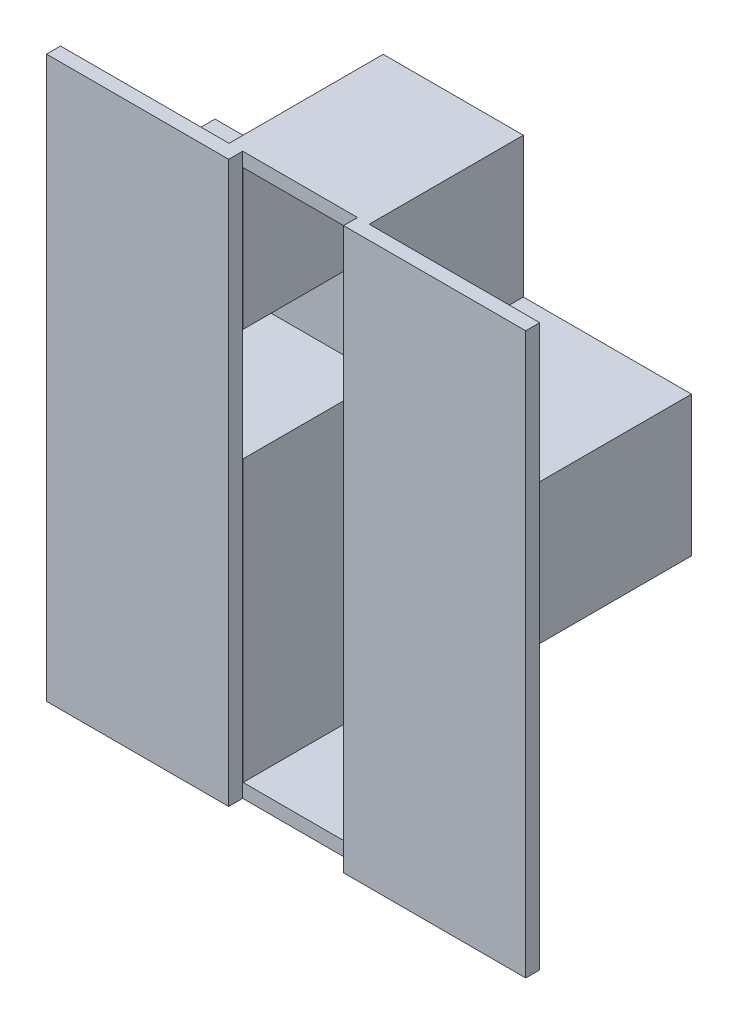
from build123d import *

# Parameters (mm, degrees)
BOSS_EXTRU_2_DEPTH = 5
BOSS_EXTRU_3_DEPTH = 50
ESQUISSE3_W        = 65
ESQUISSE3_H        = 200
BOSS_EXTRU_7_DEPTH = 5
ESQUISSE8_W        = 65
ESQUISSE8_H        = 200
BOSS_EXTRU_8_DEPTH = 5


with BuildPart() as part:
    # Esquisse1 → Boss.-Extru.2 (new body)
    with BuildSketch(Plane.XY):
        Polygon((-50, 100), (-110, 100), (-110, 150), (-50, 150), (-50, 200), (0, 200), (0, 150), (60, 150), (60, 100), (0, 100), (0, 0), (-50, 0), align=None)
    extrude(amount=BOSS_EXTRU_2_DEPTH)

    # Esquisse2 → Boss.-Extru.3 (add)
    with BuildSketch(Plane.XY.offset(5)):
        Polygon((-110, 150), (-110, 100), (-50, 100), (-50, 0), (0, 0), (0, 100), (60, 100), (60, 150), (0, 150), (0, 200), (-50, 200), (-50, 150), align=None)
        Polygon((-105, 145), (-105, 105), (-45, 105), (-45, 5), (-5, 5), (-5, 105), (55, 105), (55, 145), (-5, 145), (-5, 195), (-45, 195), (-45, 145), align=None, mode=Mode.SUBTRACT)
    extrude(amount=BOSS_EXTRU_3_DEPTH)

    # Esquisse3 → Boss.-Extru.7 (add)
    with BuildSketch(Plane.XY.offset(55)):
        with Locations((-77.636000324, 100)):
            Rectangle(ESQUISSE3_W, ESQUISSE3_H)
    extrude(amount=BOSS_EXTRU_7_DEPTH)

    # Esquisse8 → Boss.-Extru.8 (add)
    with BuildSketch(Plane.XY.offset(55)):
        with Locations((28.350884712, 100)):
            Rectangle(ESQUISSE8_W, ESQUISSE8_H)
    extrude(amount=BOSS_EXTRU_8_DEPTH)


solid = part.part
